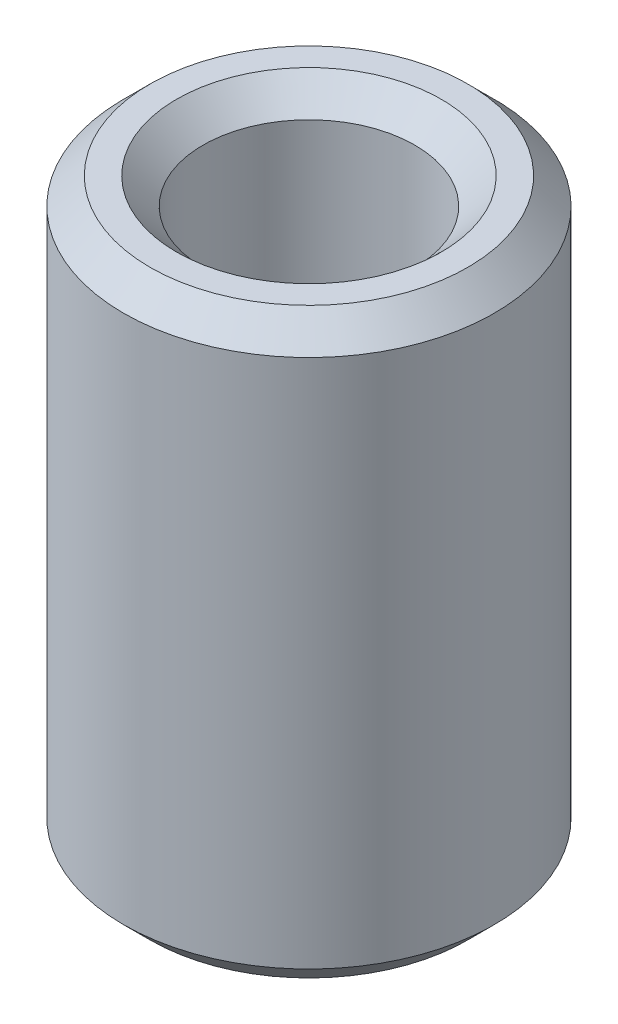
from build123d import *

# Parameters (mm, degrees)
SKETCH1_R           = 7
SKETCH1_R_2         = 4
BOSS_EXTRUDE1_DEPTH = 22
CHAMFER1_SIZE       = 1


with BuildPart() as part:
    # Sketch1 → Boss-Extrude1 (new body)
    with BuildSketch(Plane(origin=(0, 0, 0), x_dir=(1, 0, 0), z_dir=(0, 1, 0))):
        Circle(SKETCH1_R)
        Circle(SKETCH1_R_2, mode=Mode.SUBTRACT)
    extrude(amount=BOSS_EXTRUDE1_DEPTH)

    # Chamfer1
    chamfer1_edges = [part.edges().sort_by_distance(p)[0] for p in [
        (-7, 0, 0),
        (-7, 22, 0),
        (-4, 0, 0),
        (-4, 22, 0),
    ]]
    chamfer(chamfer1_edges, length=CHAMFER1_SIZE)


solid = part.part
